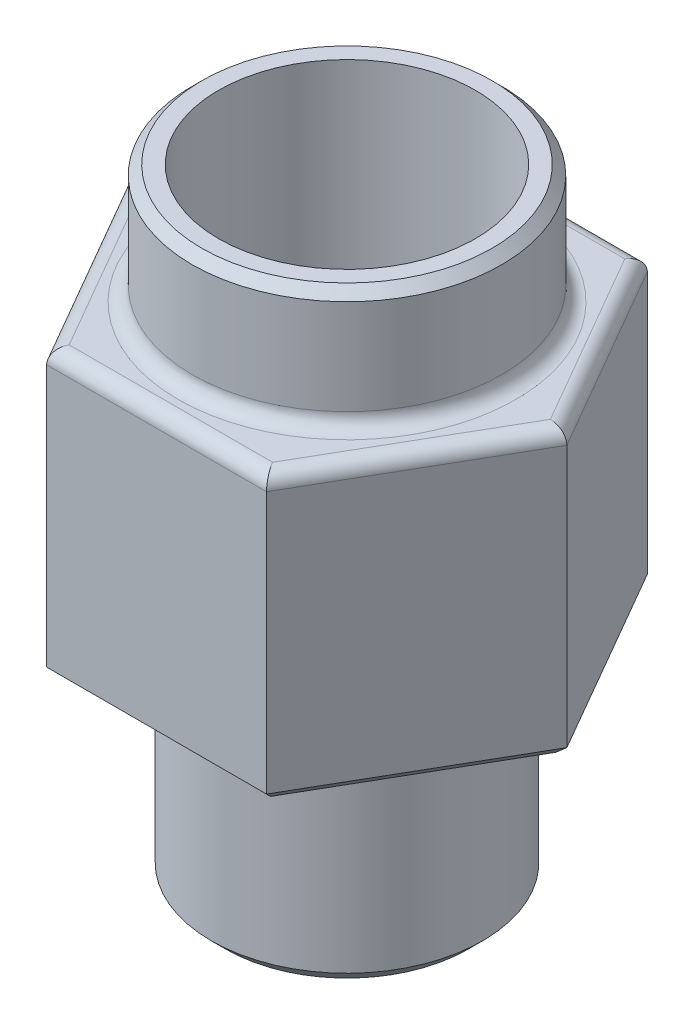
from build123d import *

# Parameters (mm, degrees)
SKETCH_1_R          = 2.85
EXTRUDE_1_DEPTH     = 4.5
EXTRUDE_2_DEPTH     = 6
SKETCH_3_R          = 3.25
EXTRUDE_3_DEPTH     = 2.5
CHAMFER_3_SIZE      = 0.2
FILLET_2_R          = 0.3
CHAMFER_4_SIZE      = 0.2
CHAMFER_5_SIZE      = 0.3
SKETCH_5_R          = 2.7
CUT_EXTRUDE_1_DEPTH = 5


with BuildPart() as part:
    # 草图1 → 凸台-拉伸1 (new body)
    with BuildSketch(Plane(origin=(0, 0, 0), x_dir=(1, 0, 0), z_dir=(0, 1, 0))):
        Circle(SKETCH_1_R)
    extrude(amount=EXTRUDE_1_DEPTH)

    # 草图2 → 凸台-拉伸2 (add)
    with BuildSketch(Plane(origin=(0, 4.5, 0), x_dir=(1, 0, 0), z_dir=(0, 1, 0))):
        Polygon((4.618802154, 0), (2.309401077, 4), (-2.309401077, 4), (-4.618802154, 0), (-2.309401077, -4), (2.309401077, -4), align=None)
    extrude(amount=EXTRUDE_2_DEPTH)

    # 草图3 → 凸台-拉伸3 (add)
    with BuildSketch(Plane(origin=(0, 10.5, 0), x_dir=(1, 0, 0), z_dir=(0, 1, 0))):
        Circle(SKETCH_3_R)
    extrude(amount=EXTRUDE_3_DEPTH)

    # 倒角3
    chamfer_3_edges = [part.edges().sort_by_distance(p)[0] for p in [
        (-2.85, 4.5, 0),
        (3.464101615, 4.5, 2),
        (3.464101615, 4.5, -2),
        (0, 4.5, -4),
        (-3.464101615, 4.5, -2),
        (-3.464101615, 4.5, 2),
        (0, 4.5, 4),
    ]]
    chamfer(chamfer_3_edges, length=CHAMFER_3_SIZE)

    # 圆角2
    fillet_2_edges = [part.edges().sort_by_distance(p)[0] for p in [
        (-3.25, 10.5, 0),
        (3.464101615, 10.5, 2),
        (3.464101615, 10.5, -2),
        (0, 10.5, -4),
        (-3.464101615, 10.5, -2),
        (-3.464101615, 10.5, 2),
        (0, 10.5, 4),
    ]]
    fillet(fillet_2_edges, radius=FILLET_2_R)

    # 倒角4
    chamfer_4_edges = [part.edges().sort_by_distance(p)[0] for p in [
        (-3.25, 13, 0),
    ]]
    chamfer(chamfer_4_edges, length=CHAMFER_4_SIZE)

    # 倒角5
    chamfer_5_edges = [part.edges().sort_by_distance(p)[0] for p in [
        (-2.85, 0, 0),
    ]]
    chamfer(chamfer_5_edges, length=CHAMFER_5_SIZE)

    # 草图5 → 切除-拉伸1 (cut)
    with BuildSketch(Plane(origin=(0, 13, 0), x_dir=(1, 0, 0), z_dir=(0, 1, 0))):
        Circle(SKETCH_5_R)
    extrude(amount=-CUT_EXTRUDE_1_DEPTH, mode=Mode.SUBTRACT)


solid = part.part
